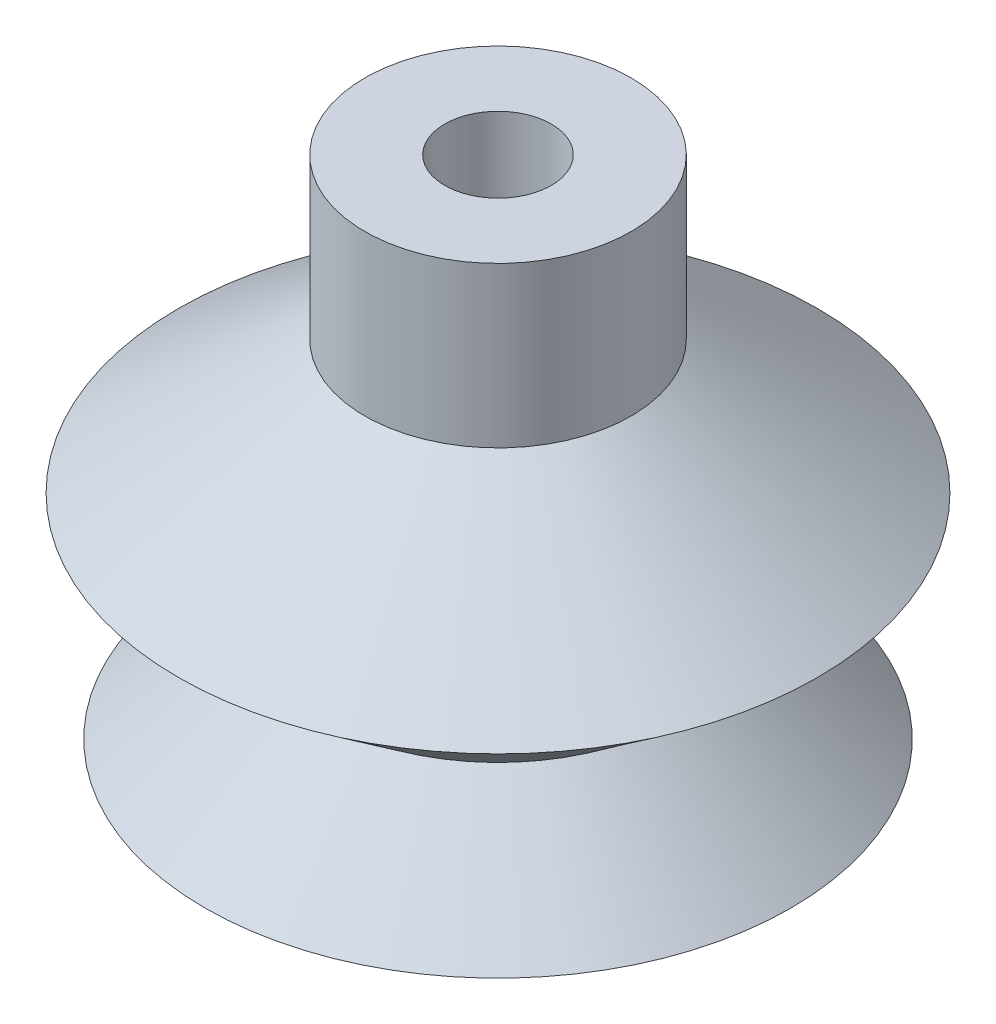
from build123d import *


with BuildPart() as part:
    # Esquisse1 → Révolution1 (revolve)
    with BuildSketch(Plane.XY):
        Polygon((5, 19), (5, 13), (12, 8), (6.738643577, 4), (11, 0), (9.538854076, 0), (5.277497653, 4), (10, 8), (3.688648935, 10), (2, 10), (2, 19), align=None)
    revolve(axis=Axis((0, 0, 0), (0, 1, 0)))


solid = part.part
